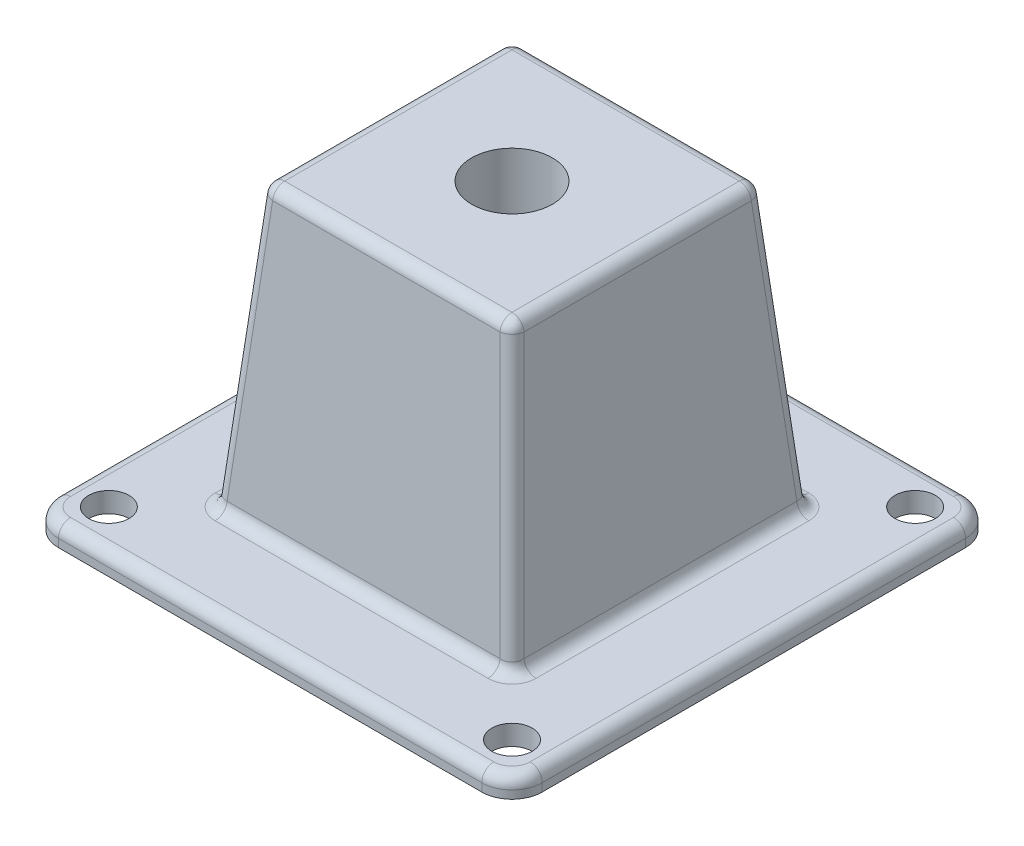
from build123d import *

# Parameters (mm, degrees)
SKETCH1_R           = 10
BOSS_EXTRUDE1_DEPTH = 10
SKETCH2_W           = 150
SKETCH2_H           = 150
BOSS_EXTRUDE2_DEPTH = 150
BOSS_EXTRUDE2_TAPER = 5
SKETCH3_R           = 20
CUT_EXTRUDE1_DEPTH  = 151.0000001
FILLET1_R           = 6


with BuildPart() as part:
    # Sketch1 → Boss-Extrude1 (new body)
    with BuildSketch(Plane(origin=(0, 0, 0), x_dir=(1, 0, 0), z_dir=(0, 1, 0))):
        with BuildLine():
            ThreePointArc((-120, -105), (-115.606601718, -115.606601718), (-105, -120))
            Line((-105, -120), (105, -120))
            ThreePointArc((105, -120), (115.606601718, -115.606601718), (120, -105))
            Line((120, -105), (120, 105))
            ThreePointArc((120, 105), (115.606601718, 115.606601718), (105, 120))
            Line((105, 120), (-105, 120))
            ThreePointArc((-105, 120), (-115.606601718, 115.606601718), (-120, 105))
            Line((-120, 105), (-120, -105))
        make_face()
        with Locations((-100, -100)):
            Circle(SKETCH1_R, mode=Mode.SUBTRACT)
        with Locations((100, -100)):
            Circle(SKETCH1_R, mode=Mode.SUBTRACT)
        with Locations((-100, 100)):
            Circle(SKETCH1_R, mode=Mode.SUBTRACT)
        with Locations((100, 100)):
            Circle(SKETCH1_R, mode=Mode.SUBTRACT)
    extrude(amount=BOSS_EXTRUDE1_DEPTH)

    # Sketch2 → Boss-Extrude2 (add)
    with BuildSketch(Plane(origin=(0, 0, 0), x_dir=(1, 0, 0), z_dir=(0, 1, 0))):
        Rectangle(SKETCH2_W, SKETCH2_H)
    extrude(amount=BOSS_EXTRUDE2_DEPTH, taper=BOSS_EXTRUDE2_TAPER)

    # Sketch3 → Cut-Extrude1 (cut, through all)
    with BuildSketch(Plane(origin=(0, 0, 0), x_dir=(1, 0, 0), z_dir=(0, 1, 0))):
        Circle(SKETCH3_R)
    extrude(amount=CUT_EXTRUDE1_DEPTH, mode=Mode.SUBTRACT)

    # Fillet1
    fillet1_edges = [part.edges().sort_by_distance(p)[0] for p in [
        (-120, 10, 0),
        (-115.606601718, 10, 115.606601718),
        (0, 10, 120),
        (115.606601718, 10, 115.606601718),
        (120, 10, 0),
        (115.606601718, 10, -115.606601718),
        (0, 10, -120),
        (74.125113365, 10, 0),
        (0, 10, -74.125113365),
        (-74.125113365, 10, 0),
        (0, 10, 74.125113365),
        (68.000906918, 80, 68.000906918),
        (68.000906918, 80, -68.000906918),
        (-68.000906918, 80, -68.000906918),
        (-68.000906918, 80, 68.000906918),
        (61.876700471, 150, 0),
        (0, 150, -61.876700471),
        (-61.876700471, 150, 0),
        (0, 150, 61.876700471),
        (-115.606601718, 10, -115.606601718),
    ]]
    fillet(fillet1_edges, radius=FILLET1_R)


solid = part.part
